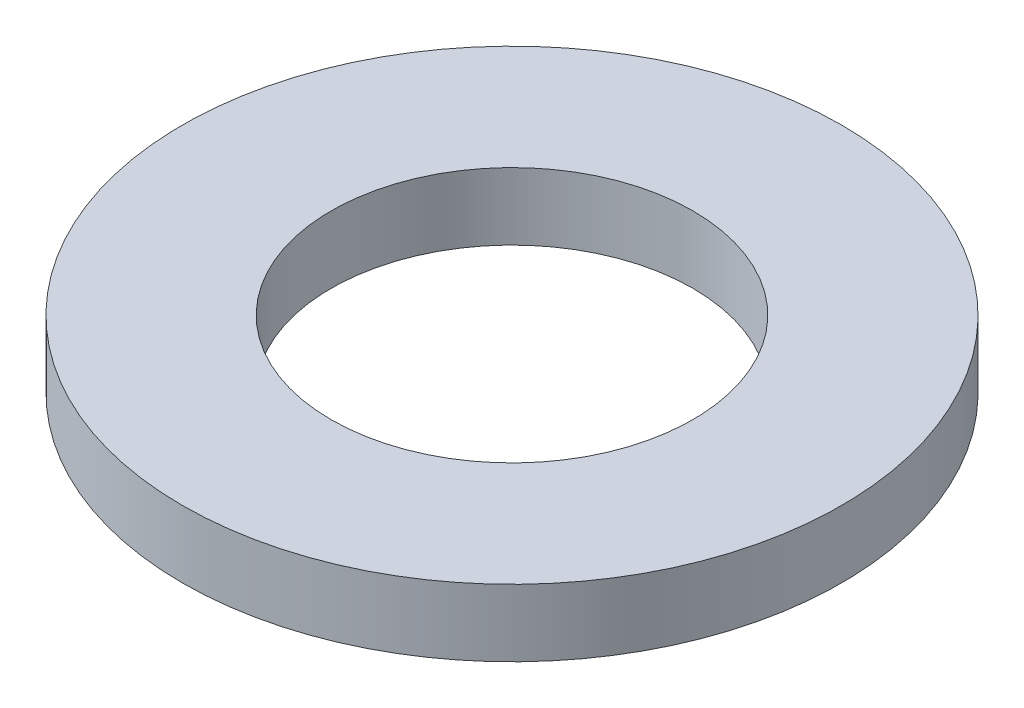
from build123d import *

# Parameters (mm, degrees)
SKETCH1_R           = 4.91
SKETCH1_R_2         = 2.695
BOSS_EXTRUDE1_DEPTH = 0.5


with BuildPart() as part:
    # Sketch1 → Boss-Extrude1 (new body, symmetric)
    with BuildSketch(Plane(origin=(0, 0, 0), x_dir=(1, 0, 0), z_dir=(0, 1, 0))):
        Circle(SKETCH1_R)
        Circle(SKETCH1_R_2, mode=Mode.SUBTRACT)
    extrude(amount=BOSS_EXTRUDE1_DEPTH, both=True)


solid = part.part
